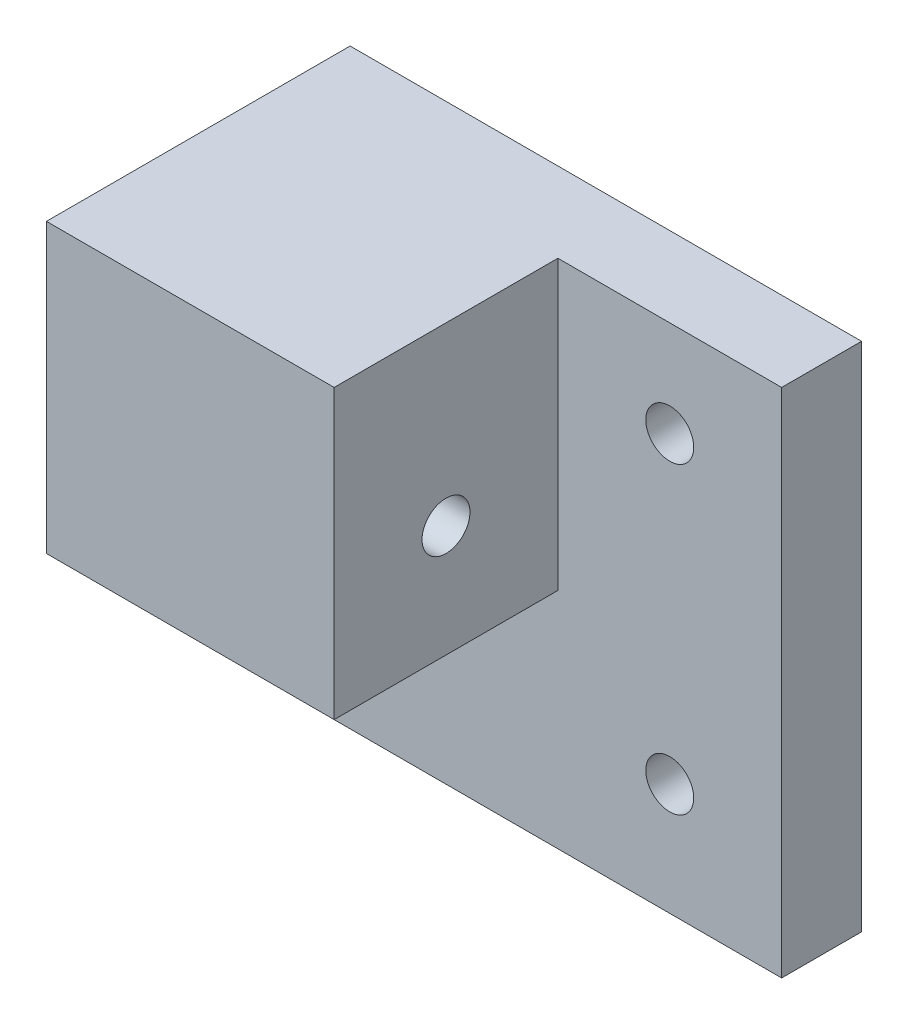
from build123d import *

# Parameters (mm, degrees)
IZIM1_W                     = 64
IZIM1_H                     = 64
Y_KSEKLIK_EKSTR_ZYON1_DEPTH = 10
IZIM2_W                     = 36
IZIM2_H                     = 36
Y_KSEKLIK_EKSTR_ZYON2_DEPTH = 28
IZIM3_R                     = 3
KES_EKSTR_ZYON1_DEPTH       = 20
IZIM4_R                     = 3
KES_EKSTR_ZYON2_DEPTH       = 20
IZIM5_R                     = 3
KES_EKSTR_ZYON3_DEPTH       = 11


with BuildPart() as part:
    # Çizim1 → Yükseklik-Ekstrüzyon1 (new body)
    with BuildSketch(Plane.XY):
        with Locations((-32, -32)):
            Rectangle(IZIM1_W, IZIM1_H)
    extrude(amount=Y_KSEKLIK_EKSTR_ZYON1_DEPTH)

    # Çizim2 → Yükseklik-Ekstrüzyon2 (add)
    with BuildSketch(Plane.XY.offset(10)):
        with Locations((-46, -18)):
            Rectangle(IZIM2_W, IZIM2_H)
    extrude(amount=Y_KSEKLIK_EKSTR_ZYON2_DEPTH)

    # Çizim3 → Kes-Ekstrüzyon1 (cut)
    with BuildSketch(Plane.XZ.offset(36)):
        with Locations((-42, 24)):
            Circle(IZIM3_R)
    extrude(amount=-KES_EKSTR_ZYON1_DEPTH, mode=Mode.SUBTRACT)

    # Çizim4 → Kes-Ekstrüzyon2 (cut)
    with BuildSketch(Plane(origin=(-28, 0, 0), x_dir=(0, 0, -1), z_dir=(1, 0, 0))):
        with Locations((-24, -22)):
            Circle(IZIM4_R)
    extrude(amount=-KES_EKSTR_ZYON2_DEPTH, mode=Mode.SUBTRACT)

    # Çizim5 → Kes-Ekstrüzyon3 (cut, through all)
    with BuildSketch(Plane.XY.offset(10)):
        with Locations((-14, -50)):
            Circle(IZIM5_R)
        with Locations((-14, -12)):
            Circle(IZIM5_R)
        with Locations((-52, -50)):
            Circle(IZIM5_R)
    extrude(amount=-KES_EKSTR_ZYON3_DEPTH, mode=Mode.SUBTRACT)


solid = part.part
